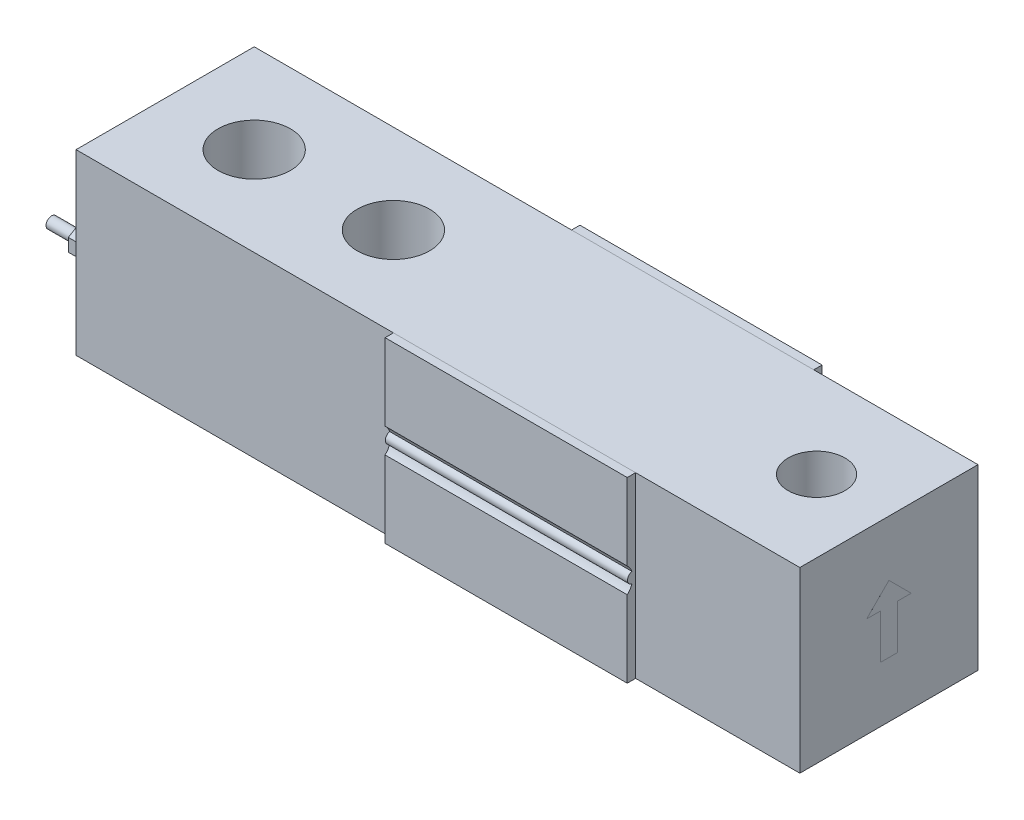
from build123d import *

# Parameters (mm, degrees)
SKETCH_1_W          = 130
SKETCH_1_H          = 32
EXTRUDE_1_DEPTH     = 32
EXTRUDE_START       = -57
EXTRUDE_2_DEPTH     = 43.5
EXTRUDE_2_2_DEPTH   = 43.5
SKETCH_3_R          = 6.5
CUT_EXTRUDE_3_DEPTH = 33
SKETCH_4_W          = 5.1
SKETCH_4_H          = 32
SKETCH_6_R          = 1.5
EXTRUDE_4_DEPTH     = 0.3
EXTRUDE_5_DEPTH     = 1.6
SKETCH_8_R          = 1
EXTRUDE_6_DEPTH     = 5
EXTRUDE_8_DEPTH     = 0.002


with BuildPart() as part:
    # Эскиз1 → Вытянуть1 (new body)
    with BuildSketch(Plane(origin=(0, 0, 0), x_dir=(1, 0, 0), z_dir=(0, 1, 0))):
        with Locations((-52, 0)):
            Rectangle(SKETCH_1_W, SKETCH_1_H)
    extrude(amount=EXTRUDE_1_DEPTH)

    # Эскиз3 → Вытянуть3 (cut, through all)
    with BuildSketch(Plane(origin=(0, 32, 0), x_dir=(1, 0, 0), z_dir=(0, 1, 0))):
        with Locations((-101, 0)):
            Circle(SKETCH_3_R)
        with Locations((-76, 0)):
            Circle(SKETCH_3_R)
    extrude(amount=-CUT_EXTRUDE_3_DEPTH, mode=Mode.SUBTRACT)

    # Эскиз4 → Отверстие обработанное метчиком M12x1.751 (revolve, cut)
    with BuildSketch(Plane(origin=(0, 32, 0), x_dir=(0, 0, 1), z_dir=(1, 0, 0))):
        with Locations((2.55, 16)):
            Rectangle(SKETCH_4_W, SKETCH_4_H)
    revolve(axis=Axis((0, 38.35, 0), (0, -1, 0)), mode=Mode.SUBTRACT)

    # Эскиз6 → Вытянуть4 (add)
    with BuildSketch(Plane.ZY.offset(117)):
        with Locations((13.5, 16)):
            Circle(SKETCH_6_R)
    extrude(amount=EXTRUDE_4_DEPTH)

    # Эскиз7 → Вытянуть5 (add)
    with BuildSketch(Plane.ZY.offset(117.3)):
        Polygon((13.5, 18.309401077), (11.5, 17.154700538), (11.5, 14.845299462), (13.5, 13.690598923), (15.5, 14.845299462), (15.5, 17.154700538), align=None)
    extrude(amount=EXTRUDE_5_DEPTH)

    # Эскиз8 → Вытянуть6 (add)
    with BuildSketch(Plane.ZY.offset(118.9)):
        with Locations((13.5, 16)):
            Circle(SKETCH_8_R)
    extrude(amount=EXTRUDE_6_DEPTH)

    # Эскиз10 → Вытянуть8 (add)
    with BuildSketch(Plane(origin=(13, 0, 0), x_dir=(0, 0, -1), z_dir=(1, 0, 0))):
        Polygon((0, 22), (-4, 18), (-1.5, 18), (-1.5, 10), (1.5, 10), (1.5, 18), (4, 18), align=None)
    extrude(amount=EXTRUDE_8_DEPTH)


with BuildPart() as body_2:
    # Эскиз2 → Вытянуть2 (new body)
    with BuildSketch(Plane.ZY.offset(117).offset(EXTRUDE_START)):
        with BuildLine():
            Line((-16, 0), (-17.5, 0))
            Line((-17.5, 0), (-17.5, 13.763932023))
            ThreePointArc((-17.5, 13.763932023), (-17.001155093, 14.339947551), (-16.66352459, 15.02306231))
            ThreePointArc((-16.66352459, 15.02306231), (-17.45, 16), (-16.66352459, 16.97693769))
            ThreePointArc((-16.66352459, 16.97693769), (-17.001155093, 17.660052449), (-17.5, 18.236067977))
            Line((-17.5, 18.236067977), (-17.5, 32))
            Line((-17.5, 32), (-16, 32))
            Line((-16, 32), (-16, 0))
        make_face()
    extrude(amount=-EXTRUDE_2_DEPTH)


with BuildPart() as body_3:
    # Эскиз2 → Extrude 2 2 (new body)
    with BuildSketch(Plane.ZY.offset(117).offset(EXTRUDE_START)):
        with BuildLine():
            Line((17.5, 18.236067977), (17.5, 32))
            Line((17.5, 32), (16, 32))
            Line((16, 32), (16, 0))
            Line((16, 0), (17.5, 0))
            Line((17.5, 0), (17.5, 13.763932023))
            ThreePointArc((17.5, 13.763932023), (17.001155093, 14.339947551), (16.66352459, 15.02306231))
            ThreePointArc((16.66352459, 15.02306231), (17.45, 16), (16.66352459, 16.97693769))
            ThreePointArc((16.66352459, 16.97693769), (17.001155093, 17.660052449), (17.5, 18.236067977))
        make_face()
    extrude(amount=-EXTRUDE_2_2_DEPTH)


solid = Compound([part.part, body_2.part, body_3.part])
